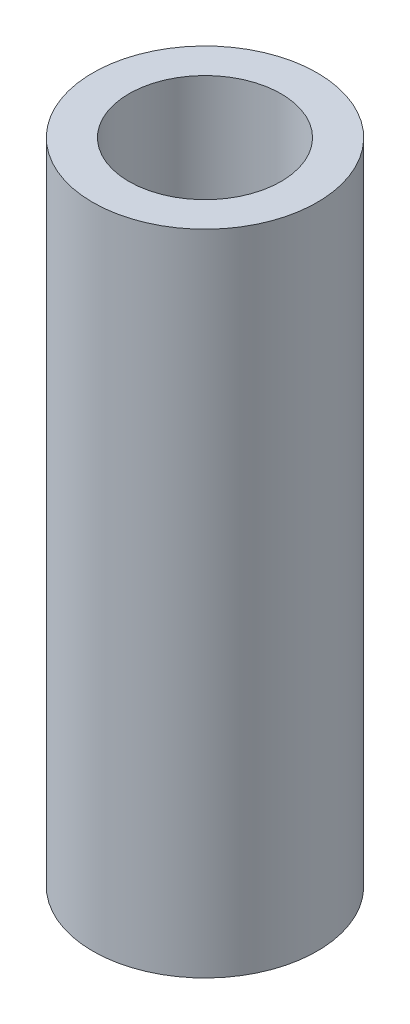
from build123d import *

# Parameters (mm, degrees)
SKETCH1_W = 1.45
SKETCH1_H = 26


with BuildPart() as part:
    # Sketch1 → Revolve1 (revolve)
    with BuildSketch(Plane.XY):
        with Locations((-3.775, -17.801692553)):
            Rectangle(SKETCH1_W, SKETCH1_H)
    revolve(axis=Axis((0, 58.538116559, 0), (0, -1, 0)))


solid = part.part
